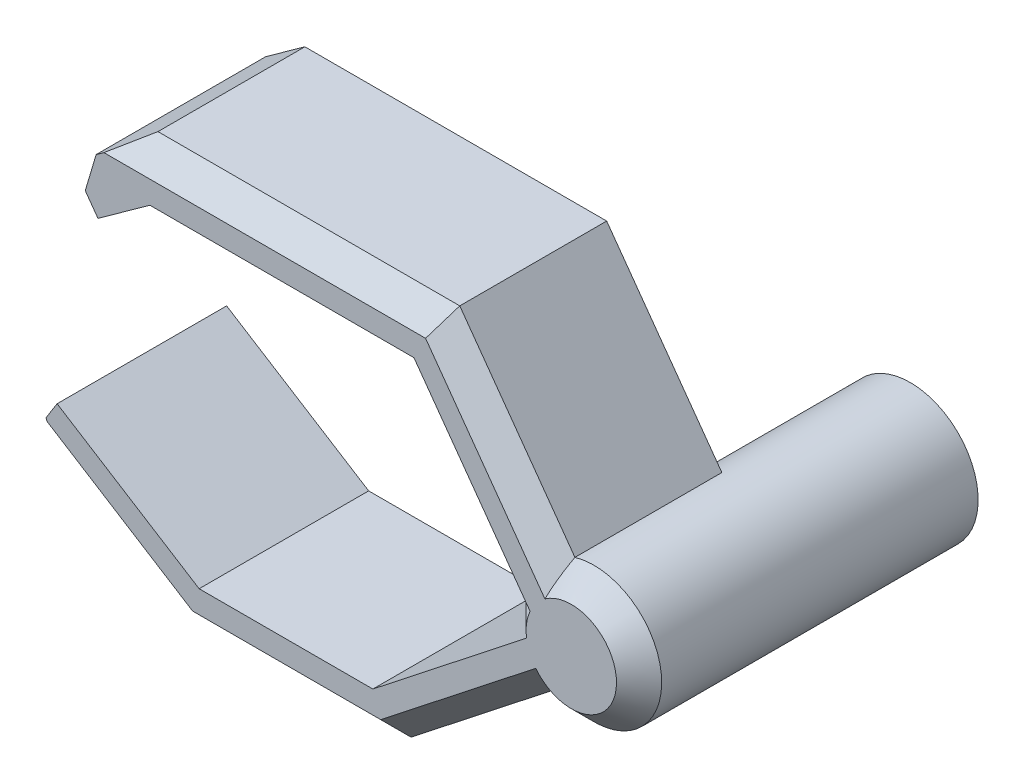
from build123d import *

# Parameters (mm, degrees)
SKETCH1_R           = 6
BOSS_EXTRUDE1_DEPTH = 15
BOSS_EXTRUDE2_DEPTH = 15
CHAMFER1_SIZE       = 2
SKETCH3_R           = 6
BOSS_EXTRUDE3_DEPTH = 15


with BuildPart() as part:
    # Sketch1 → Boss-Extrude1 (new body)
    with BuildSketch(Plane.XY):
        Circle(SKETCH1_R)
    extrude(amount=BOSS_EXTRUDE1_DEPTH)

    # Sketch2 → Boss-Extrude2 (add)
    with BuildSketch(Plane.XY.offset(15)):
        Polygon((-34.083999274, -15.270349256), (-45.136951092, -8.328867942), (-46.483233706, -4.941481314), (-45.500714563, -3.377011677), (-32.932117748, -11.270349256), (-17.560265153, -11.270349256), (-2.741776156, 0.387724819), (-13.920336004, 15.939232255), (-37.288016477, 15.939232255), (-41.885217055, 12.634724187), (-43.009602546, 14.198958718), (-42.043738714, 17.446929746), (-38.576470878, 19.939232255), (-11.869418747, 19.939232255), (2.741776156, -0.387724819), (-16.1754142, -15.270349256), align=None)
    extrude(amount=-BOSS_EXTRUDE2_DEPTH)

    # Chamfer1
    chamfer1_edges = [part.edges().sort_by_distance(p)[0] for p in [
        (-6.773577635, 12.849945977, 15),
        (-25.222944812, 19.939232255, 15),
        (-39.610475183, -11.799608599, 15),
        (-25.129706737, -15.270349256, 15),
        (-9.692346894, -10.169958865, 15),
        (-5.940891532, 0.840123687, 15),
        (5.940891532, -0.840123687, 15),
    ]]
    chamfer(chamfer1_edges, length=CHAMFER1_SIZE)

    # Sketch3 → Boss-Extrude3 (add)
    with BuildSketch(Plane(origin=(0, 0, 0), x_dir=(-1, 0, 0), z_dir=(0, 0, -1))):
        Circle(SKETCH3_R)
    extrude(amount=BOSS_EXTRUDE3_DEPTH)


solid = part.part
